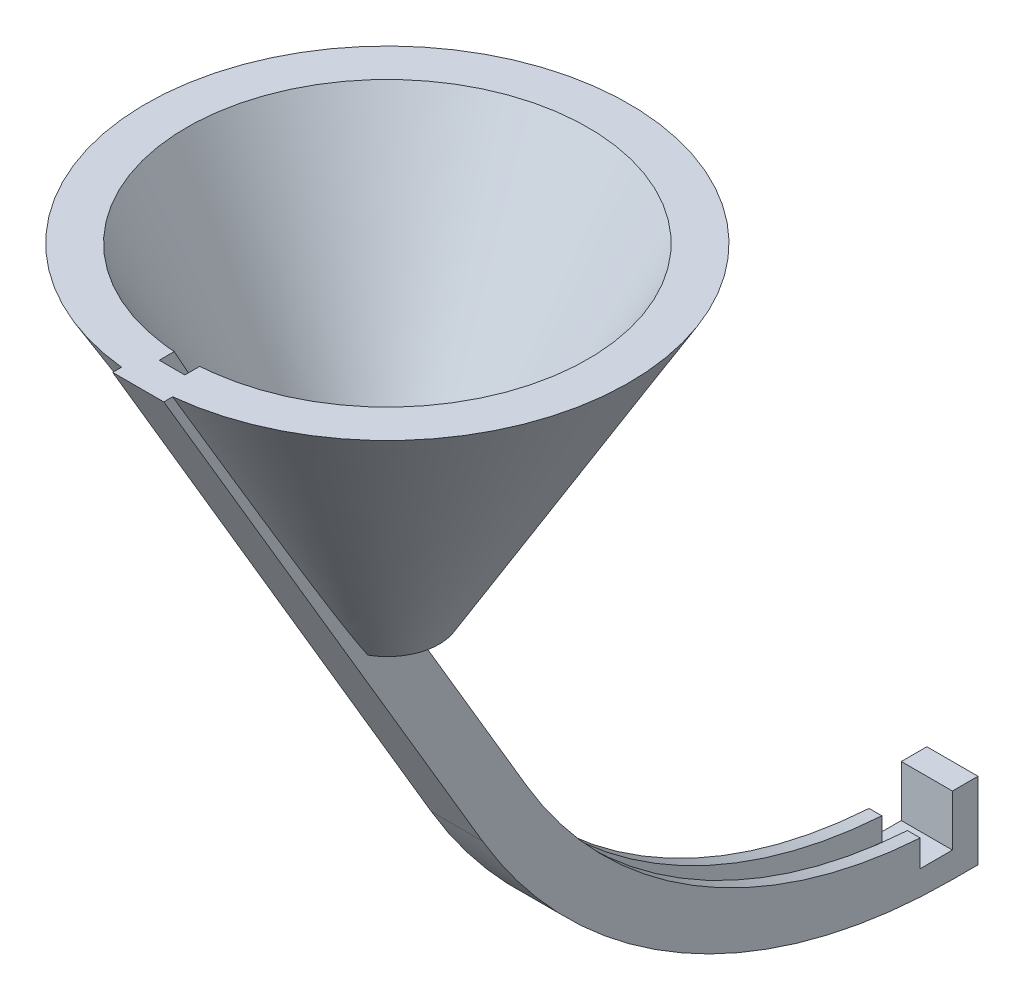
from build123d import *

# Parameters (mm, degrees)
SKETCH5_W           = 12.880016042
SKETCH5_H           = 15.834691301
CUT_EXTRUDE2_DEPTH  = 7.62
BOSS_EXTRUDE1_DEPTH = 3.175
CUT_EXTRUDE4_DEPTH  = 1.5875
SKETCH10_W          = 4
SKETCH10_H          = 3.30542238
CUT_EXTRUDE5_DEPTH  = 34.174999944


with BuildPart() as part:
    # Sketch2 → Revolve1 (revolve)
    with BuildSketch(Plane(origin=(0, 0, 0), x_dir=(0, 0, -1), z_dir=(1, 0, 0))):
        Polygon((0, -50.8), (-29.999999944, 0), (0, 0), align=None)
    revolve(axis=Axis((0, 0, 0), (0, -1, 0)))

    # Sketch4 → Cut-Revolve1 (revolve, cut)
    with BuildSketch(Plane(origin=(0, 0, 0), x_dir=(0, 0, -1), z_dir=(1, 0, 0))):
        Polygon((0, -45.72), (-24.919999944, 0), (0, 0), align=None)
    revolve(axis=Axis((0, 16.11457811, 0), (0, -1, 0)), mode=Mode.SUBTRACT)

    # Sketch5 → Cut-Extrude2 (cut, symmetric)
    with BuildSketch(Plane(origin=(0, 0, 0), x_dir=(0, 0, -1), z_dir=(1, 0, 0))):
        with Locations((0, -47.812265381)):
            Rectangle(SKETCH5_W, SKETCH5_H)
    extrude(amount=CUT_EXTRUDE2_DEPTH, both=True, mode=Mode.SUBTRACT)

    # Sketch6 → Boss-Extrude1 (add, symmetric)
    with BuildSketch(Plane(origin=(0, 0, 0), x_dir=(0, 0, -1), z_dir=(1, 0, 0))):
        with BuildLine():
            Line((0, -39.89491973), (-7.374618631, -39.89491973))
            Line((-7.374618631, -39.89491973), (8.649316149, -67.028782674))
            ThreePointArc((8.649316149, -67.028782674), (24.995151659, -85.745993658), (46.99, -97.31089625))
            ThreePointArc((46.99, -97.31089625), (56.876704451, -99.570972509), (66.99, -100.33))
            Line((66.99, -100.33), (70.165, -100.33))
            Line((70.165, -100.33), (70.165, -90.805))
            Line((70.165, -90.805), (66.99, -90.805))
            Line((66.99, -90.805), (66.99, -93.98))
            ThreePointArc((66.99, -93.98), (36.549925695, -85.903846215), (14.117056519, -63.799802147))
            Line((14.117056519, -63.799802147), (0, -39.89491973))
        make_face()
        Polygon((-30.934610553, 0), (-7.374618631, -39.89491973), (0, -39.89491973), (-23.559991923, 0), align=None)
    extrude(amount=BOSS_EXTRUDE1_DEPTH, both=True)

    # Sketch7 → Cut-Extrude4 (cut)
    with BuildSketch(Plane(origin=(0, 0, 0), x_dir=(0, 0, -1), z_dir=(1, 0, 0))):
        with BuildLine():
            Line((-3.175, -39.89491973), (11.763026223, -65.189977515))
            ThreePointArc((11.763026223, -65.189977515), (31.846754922, -86.228834252), (59.157727955, -96.233853156))
            ThreePointArc((59.157727955, -96.233853156), (63.072632016, -96.704901626), (66.99, -97.155))
            Line((66.99, -97.155), (66.99, -93.98))
            ThreePointArc((66.99, -93.98), (58.670725699, -93.413828019), (50.504865217, -91.725752721))
            ThreePointArc((50.504865217, -91.725752721), (29.605505433, -81.288014454), (14.117056519, -63.799802147))
            Line((14.117056519, -63.799802147), (-23.559991923, 0))
            Line((-23.559991923, 0), (-26.734991923, 0))
            Line((-26.734991923, 0), (-3.175, -39.89491973))
        make_face()
    cut_extrude4 = extrude(amount=-CUT_EXTRUDE4_DEPTH, mode=Mode.SUBTRACT)

    # Mirror1: Cut-Extrude4 across plane
    add(cut_extrude4.mirror(Plane(origin=(0, 0, 0), x_dir=(0, 0, 1), z_dir=(1, 0, 0))), mode=Mode.SUBTRACT)

    # Sketch9 → Cut-Revolve2 (revolve, cut)
    with BuildSketch(Plane(origin=(0, 0, 0), x_dir=(0, 0, -1), z_dir=(1, 0, 0))):
        Polygon((0, 0), (-24.9199908, 0), (-2.801476321, -39.89491973), (0, -39.89491973), align=None)
    revolve(axis=Axis((0, 16.11457811, 0), (0, -1, 0)), mode=Mode.SUBTRACT)

    # Sketch10 → Cut-Extrude5 (cut, through all)
    with BuildSketch(Plane.ZY.offset(3.175)):
        with Locations((-64.99, -95.50228881)):
            Rectangle(SKETCH10_W, SKETCH10_H)
    extrude(amount=-CUT_EXTRUDE5_DEPTH, mode=Mode.SUBTRACT)


solid = part.part
